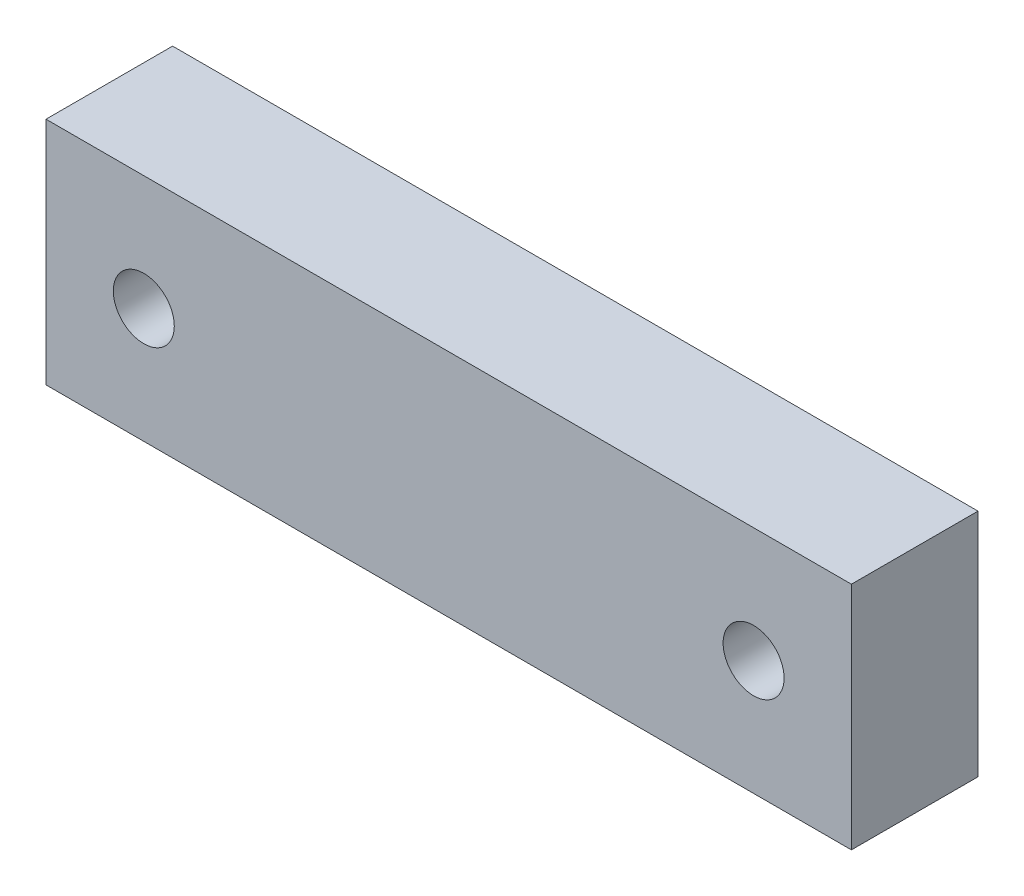
from build123d import *

# Parameters (mm, degrees)
SKETCH1_W      = 70
SKETCH1_H      = 20
SKETCH1_R      = 2.65
EXTRUDE1_DEPTH = 11.002873


with BuildPart() as part:
    # Sketch1 → Extrude1 (new body)
    with BuildSketch(Plane.XY):
        with Locations((0, -52.5)):
            Rectangle(SKETCH1_W, SKETCH1_H)
        with Locations((26.5, -52.5)):
            Circle(SKETCH1_R, mode=Mode.SUBTRACT)
        with Locations((-26.5, -52.5)):
            Circle(SKETCH1_R, mode=Mode.SUBTRACT)
    extrude(amount=EXTRUDE1_DEPTH)


solid = part.part
